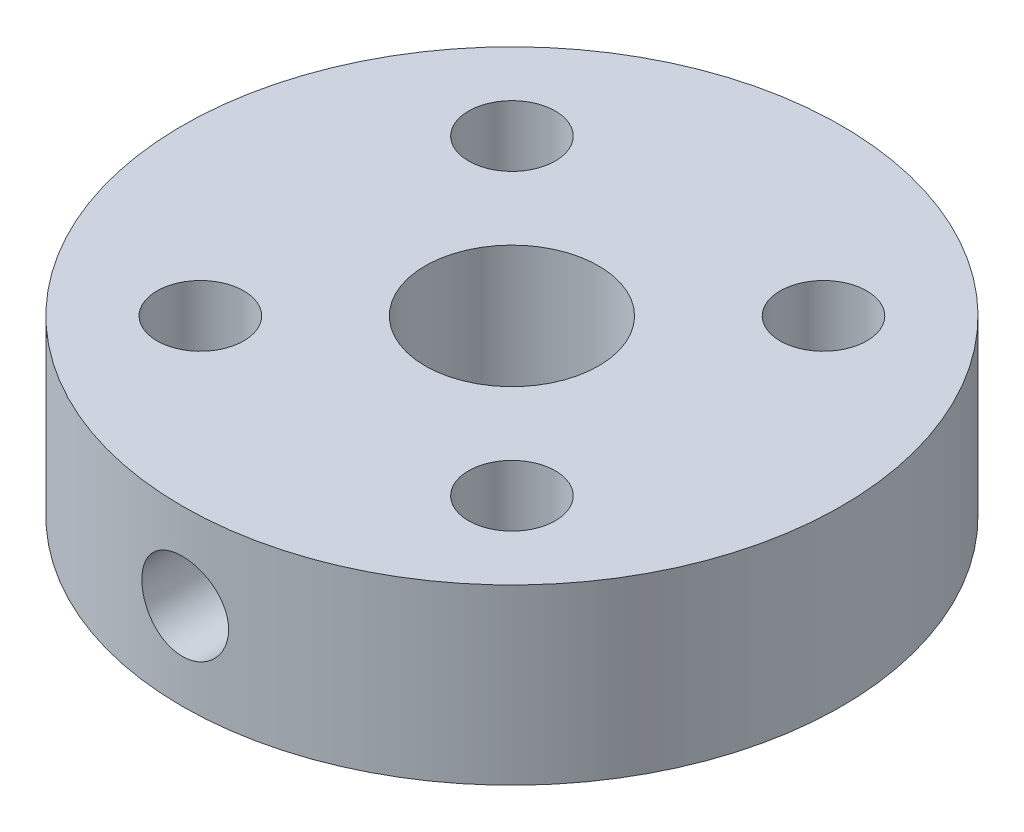
from build123d import *

# Parameters (mm, degrees)
SKETCH1_R                 = 9.5
BOSS_EXTRUDE1_DEPTH       = 5
F_5_0MM_DOWEL_HOLE1_D     = 5
M3X0_5_TAPPED_HOLE1_D     = 2.5
M3X0_5_TAPPED_HOLE2_D     = 2.5
M3X0_5_TAPPED_HOLE2_DEPTH = 10
M3X0_5_TAPPED_HOLE2_TIP   = 0.751075774


with BuildPart() as part:
    # Sketch1 → Boss-Extrude1 (new body)
    with BuildSketch(Plane(origin=(0, 0, 0), x_dir=(1, 0, 0), z_dir=(0, 1, 0))):
        Circle(SKETCH1_R)
    extrude(amount=BOSS_EXTRUDE1_DEPTH)

    # Ø5.0mm Dowel Hole1 (through all)
    with Locations(Plane(origin=(0, 5, 0), x_dir=(1, 0, 0), z_dir=(0, 1, 0))):
        with Locations((0, 0)):
            Hole(F_5_0MM_DOWEL_HOLE1_D / 2)

    # M3x0.5 Tapped Hole1 (through all)
    with Locations(Plane(origin=(0, 5, 0), x_dir=(1, 0, 0), z_dir=(0, 1, 0))):
        with Locations((4.490128061, 4.490128061), (-4.490128061, 4.490128061), (-4.490128061, -4.490128061), (4.490128061, -4.490128061)):
            Hole(M3X0_5_TAPPED_HOLE1_D / 2)

    # M3x0.5 Tapped Hole2
    with Locations(Plane(origin=(0, 2.5, 9.5), x_dir=(1, 0, 0), z_dir=(0, 0, 1))):
        with Locations((0, 0)):
            Hole(M3X0_5_TAPPED_HOLE2_D / 2, depth=M3X0_5_TAPPED_HOLE2_DEPTH)
            with Locations((0, 0, -(M3X0_5_TAPPED_HOLE2_DEPTH + M3X0_5_TAPPED_HOLE2_TIP / 2))):  # 118° drill point
                Cone(0, M3X0_5_TAPPED_HOLE2_D / 2, M3X0_5_TAPPED_HOLE2_TIP, mode=Mode.SUBTRACT)


solid = part.part
